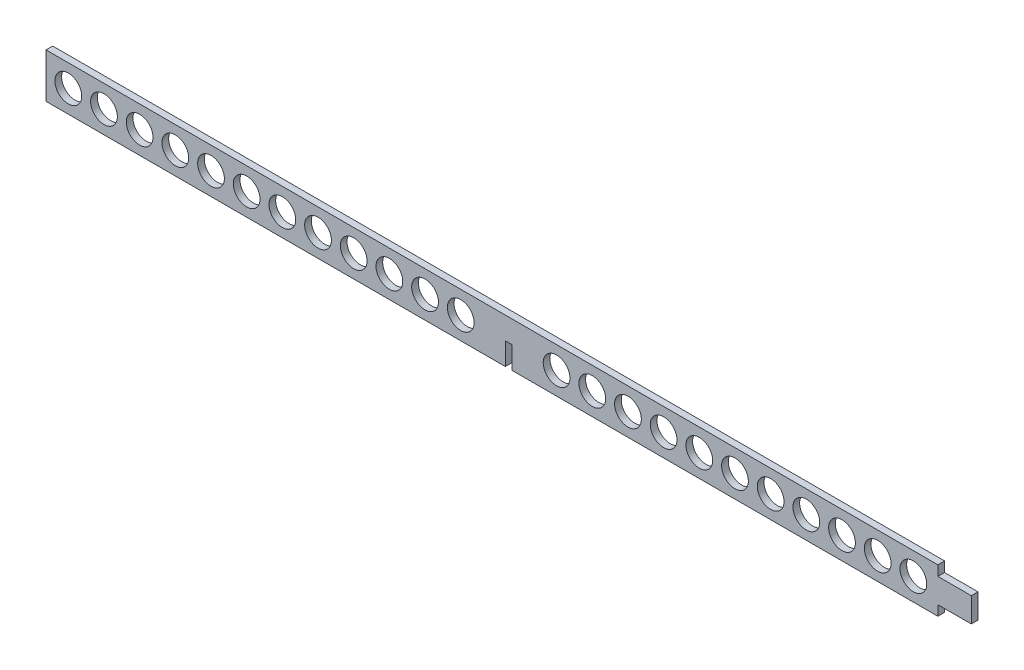
from build123d import *

# Parameters (mm, degrees)
SKETCH1_W               = 415
SKETCH1_H               = 20
BOSS_EXTRUDE1_DEPTH     = 3
SKETCH2_R               = 6
SKETCH2_W               = 15
SKETCH2_H               = 4.5
SKETCH2_W_2             = 3
SKETCH2_H_2             = 10
CUT_EXTRUDE1_DEPTH      = 1
CUT_EXTRUDE1_DEPTH_BACK = 4


with BuildPart() as part:
    # Sketch1 → Boss-Extrude1 (new body)
    with BuildSketch(Plane.XY):
        with Locations((-207.5, 10)):
            Rectangle(SKETCH1_W, SKETCH1_H)
    extrude(amount=BOSS_EXTRUDE1_DEPTH)

    # Sketch2 → Cut-Extrude1 (cut, two sides)
    with BuildSketch(Plane.XY.offset(3)) as cut_extrude1_sk:
        with Locations((-405, 10)):
            Circle(SKETCH2_R)
        with Locations((-389, 10)):
            Circle(SKETCH2_R)
        with Locations((-373, 10)):
            Circle(SKETCH2_R)
        with Locations((-357, 10)):
            Circle(SKETCH2_R)
        with Locations((-341, 10)):
            Circle(SKETCH2_R)
        with Locations((-325, 10)):
            Circle(SKETCH2_R)
        with Locations((-309, 10)):
            Circle(SKETCH2_R)
        with Locations((-293, 10)):
            Circle(SKETCH2_R)
        with Locations((-277, 10)):
            Circle(SKETCH2_R)
        with Locations((-261, 10)):
            Circle(SKETCH2_R)
        with Locations((-245, 10)):
            Circle(SKETCH2_R)
        with Locations((-229, 10)):
            Circle(SKETCH2_R)
        with Locations((-26, 10)):
            Circle(SKETCH2_R)
        with Locations((-42, 10)):
            Circle(SKETCH2_R)
        with Locations((-58, 10)):
            Circle(SKETCH2_R)
        with Locations((-74, 10)):
            Circle(SKETCH2_R)
        with Locations((-90, 10)):
            Circle(SKETCH2_R)
        with Locations((-106, 10)):
            Circle(SKETCH2_R)
        with Locations((-122, 10)):
            Circle(SKETCH2_R)
        with Locations((-138, 10)):
            Circle(SKETCH2_R)
        with Locations((-154, 10)):
            Circle(SKETCH2_R)
        with Locations((-170, 10)):
            Circle(SKETCH2_R)
        with Locations((-186, 10)):
            Circle(SKETCH2_R)
        with Locations((-7.5, 17.75)):
            Rectangle(SKETCH2_W, SKETCH2_H)
        with Locations((-7.5, 2.25)):
            Rectangle(SKETCH2_W, SKETCH2_H)
        with Locations((-207.5, 5)):
            Rectangle(SKETCH2_W_2, SKETCH2_H_2)
    extrude(amount=CUT_EXTRUDE1_DEPTH, mode=Mode.SUBTRACT)
    extrude(cut_extrude1_sk.sketch, amount=-CUT_EXTRUDE1_DEPTH_BACK, mode=Mode.SUBTRACT)


solid = part.part
